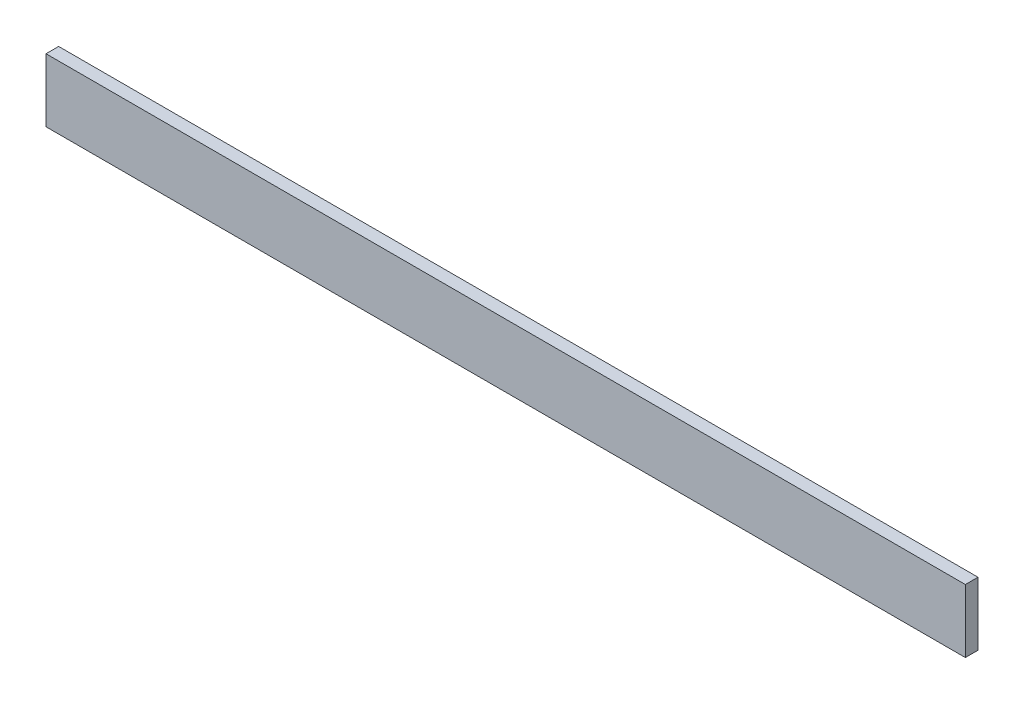
from build123d import *

# Parameters (mm, degrees)
SKETCH1_W           = 2768.6
SKETCH1_H           = 190.5
BOSS_EXTRUDE1_DEPTH = 38.1


with BuildPart() as part:
    # Sketch1 → Boss-Extrude1 (new body)
    with BuildSketch(Plane.XY):
        with Locations((1384.3, 95.25)):
            Rectangle(SKETCH1_W, SKETCH1_H)
    extrude(amount=BOSS_EXTRUDE1_DEPTH)


solid = part.part
